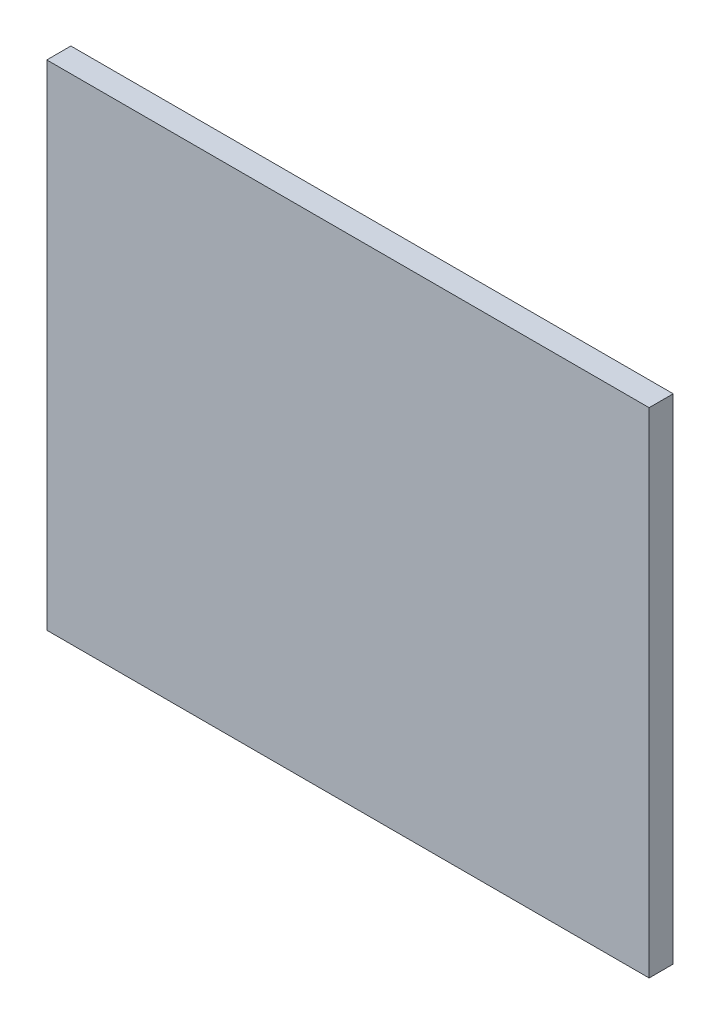
from build123d import *

# Parameters (mm, degrees)
SKETCH1_W           = 25
SKETCH1_H           = 20.5
BOSS_EXTRUDE1_DEPTH = 1


with BuildPart() as part:
    # Sketch1 → Boss-Extrude1 (new body)
    with BuildSketch(Plane.XY):
        with Locations((7.5, 0)):
            Rectangle(SKETCH1_W, SKETCH1_H)
    extrude(amount=BOSS_EXTRUDE1_DEPTH)


solid = part.part
